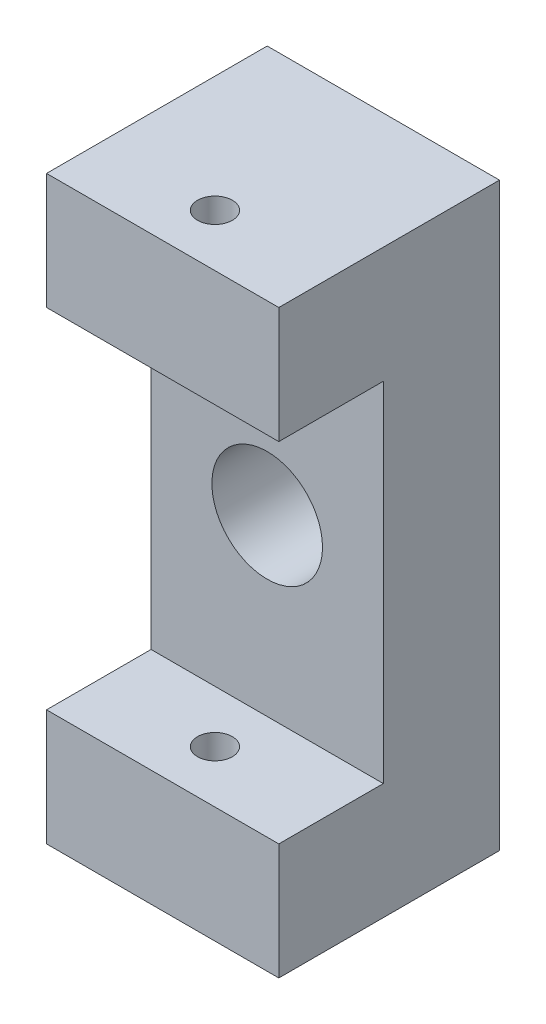
from build123d import *

# Parameters (mm, degrees)
SKETCH1_W           = 20
SKETCH1_H           = 30
SKETCH1_R           = 4.7625
BOSS_EXTRUDE1_DEPTH = 10
SKETCH2_W           = 20
SKETCH2_H           = 10
BOSS_EXTRUDE2_DEPTH = 19
SKETCH3_R           = 1.5
CUT_EXTRUDE1_DEPTH  = 51


with BuildPart() as part:
    # Sketch1 → Boss-Extrude1 (new body)
    with BuildSketch(Plane.XY):
        with Locations((10, 15)):
            Rectangle(SKETCH1_W, SKETCH1_H)
        with Locations((10, 15)):
            Circle(SKETCH1_R, mode=Mode.SUBTRACT)
    extrude(amount=BOSS_EXTRUDE1_DEPTH)

    # Sketch2 → Boss-Extrude2 (add)
    with BuildSketch(Plane.XY):
        with Locations((10, -5)):
            Rectangle(SKETCH2_W, SKETCH2_H)
        with Locations((10, 35)):
            Rectangle(SKETCH2_W, SKETCH2_H)
    extrude(amount=BOSS_EXTRUDE2_DEPTH)

    # Sketch3 → Cut-Extrude1 (cut, through all)
    with BuildSketch(Plane(origin=(0, 40, 0), x_dir=(1, 0, 0), z_dir=(0, 1, 0))):
        with Locations((10, -14.5)):
            Circle(SKETCH3_R)
    extrude(amount=-CUT_EXTRUDE1_DEPTH, mode=Mode.SUBTRACT)


solid = part.part
